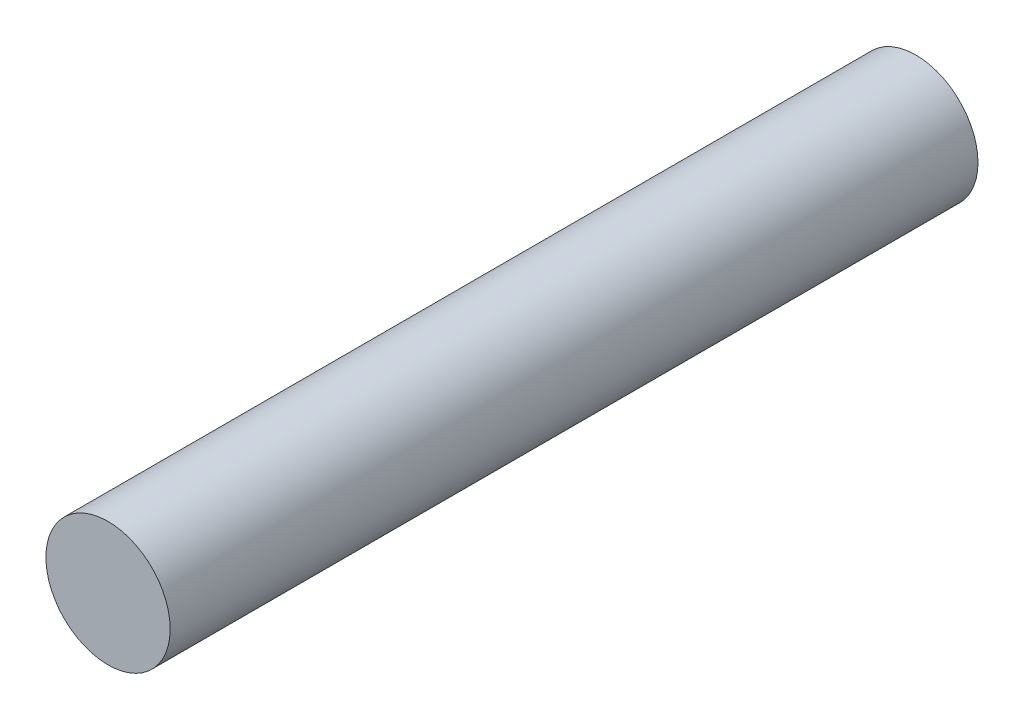
from build123d import *

# Parameters (mm, degrees)
SKETCH1_R           = 4
BOSS_EXTRUDE1_DEPTH = 26


with BuildPart() as part:
    # Sketch1 → Boss-Extrude1 (new body)
    with BuildSketch(Plane(origin=(0, 0, 0), x_dir=(0, 1, 0), z_dir=(0, 0, 1))):
        Circle(SKETCH1_R)
    extrude(amount=BOSS_EXTRUDE1_DEPTH)

    # Mirror1: part across plane


with BuildPart() as part_1:
    add(part.part)
    add(part.part.mirror(Plane.XY))


solid = part_1.part
